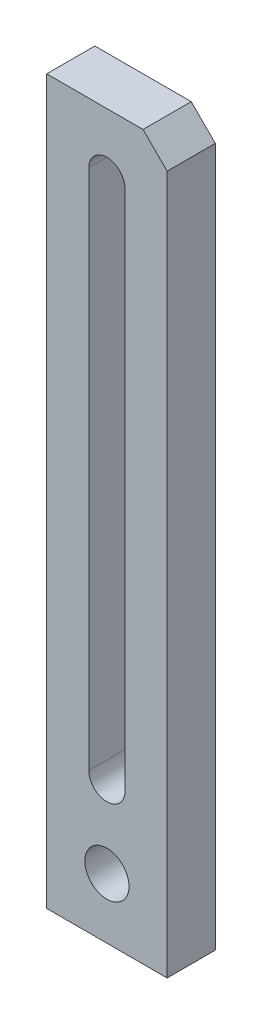
from build123d import *

# Parameters (mm, degrees)
SKETCH_1_W          = 30
SKETCH_1_H          = 180
EXTRUDE_1_DEPTH     = 12
SKETCH_2_R          = 5.5
CUT_EXTRUDE_1_DEPTH = 12
CHAMFER_1_SIZE      = 6


with BuildPart() as part:
    # 草图1 → 凸台-拉伸1 (new body)
    with BuildSketch(Plane.XY):
        Rectangle(SKETCH_1_W, SKETCH_1_H)
    extrude(amount=EXTRUDE_1_DEPTH)

    # 草图2 → 切除-拉伸1 (cut)
    with BuildSketch(Plane.XY.offset(12)):
        with Locations((0, -75)):
            Circle(SKETCH_2_R)
        with BuildLine():
            Line((4.5, 75), (4.5, -55))
            ThreePointArc((4.5, -55), (0, -59.5), (-4.5, -55))
            Line((-4.5, -55), (-4.5, 75))
            ThreePointArc((-4.5, 75), (0, 79.5), (4.5, 75))
        make_face()
    extrude(amount=-CUT_EXTRUDE_1_DEPTH, mode=Mode.SUBTRACT)

    # 倒角1
    chamfer_1_edges = [part.edges().sort_by_distance(p)[0] for p in [
        (15, 90, 6),
    ]]
    chamfer(chamfer_1_edges, length=CHAMFER_1_SIZE)


solid = part.part
